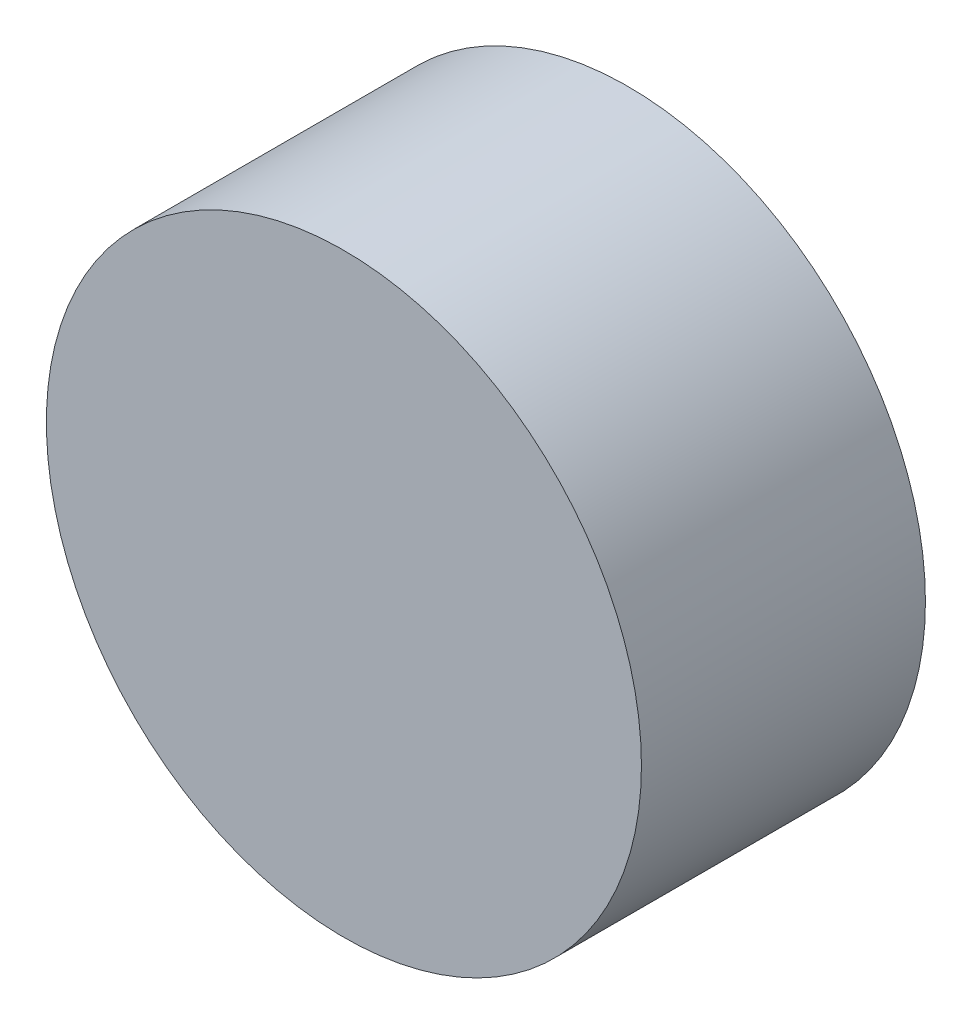
from build123d import *

# Parameters (mm, degrees)
SKETCH1_R           = 34.925
BOSS_EXTRUDE1_DEPTH = 33.3375


with BuildPart() as part:
    # Sketch1 → Boss-Extrude1 (new body)
    with BuildSketch(Plane.XY):
        Circle(SKETCH1_R)
    extrude(amount=BOSS_EXTRUDE1_DEPTH)


solid = part.part
